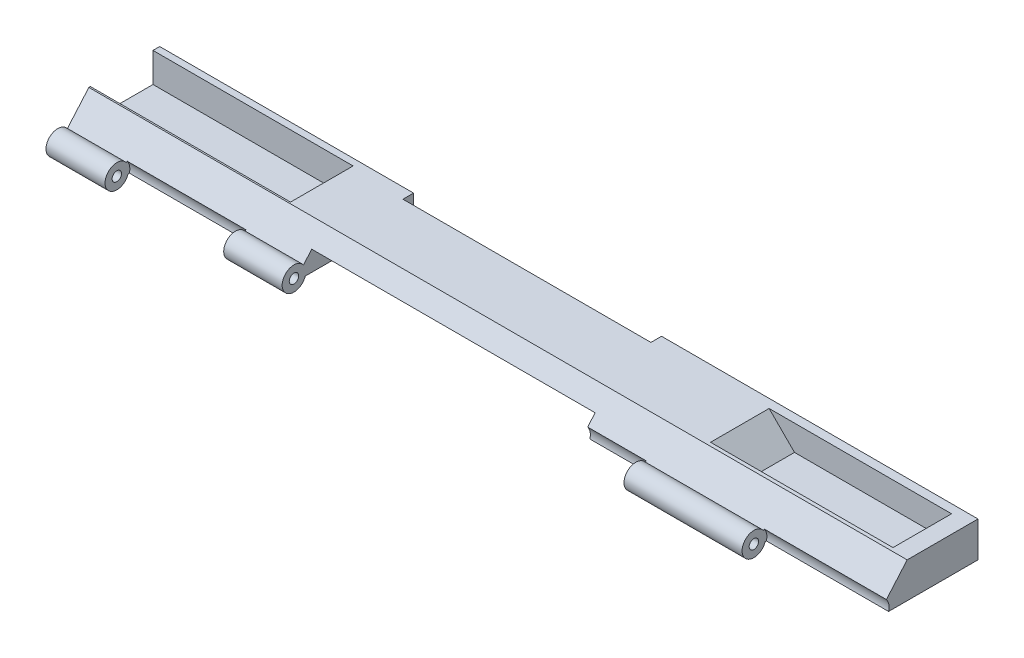
from build123d import *

# Parameters (mm, degrees)
SKETCH1_R                = 1.6002
SKETCH1_R_2              = 0.8128
BOSS_EXTRUDE5_DEPTH      = 162.56
CUT_EXTRUDE1_DEPTH       = 14.351
SKETCH3_W                = 0.889
SKETCH3_H                = 5.842
BOSS_EXTRUDE6_DEPTH      = 36.957
SKETCH16_W               = 13.462
SKETCH16_H               = 6.460130881
BOSS_EXTRUDE7_DEPTH      = 33.02
CUT_EXTRUDE4_DEPTH       = 15.24
SKETCH18_W               = 1.778
SKETCH18_H               = 5.842
BOSS_EXTRUDE8_DEPTH      = 38.1
CUT_EXTRUDE5_DEPTH       = 14.224
SKETCH20_W               = 2.1336
SKETCH20_H               = 5.461
BOSS_EXTRUDE9_DEPTH      = 36.322
SKETCH22_R               = 1.4224
CUT_EXTRUDE7_DEPTH       = 20.32
CUT_EXTRUDE7_DEPTH_BACK  = 24.13
SKETCH25_W               = 112.268
SKETCH25_H               = 3.007323321
CUT_EXTRUDE8_DEPTH       = 24.13
SKETCH27_R               = 1.778
CUT_EXTRUDE9_DEPTH       = 112.268
CUT_EXTRUDE12_DEPTH      = 14.224
SKETCH34_W               = 43.053
SKETCH34_H               = 2.1336
BOSS_EXTRUDE14_DEPTH     = 7.112
SKETCH35_R               = 1.4224
CUT_EXTRUDE13_DEPTH      = 7.112
SKETCH37_W               = 60.96
SKETCH37_H               = 15.24
CUT_EXTRUDE14_DEPTH      = 3.048
SKETCH38_R               = 0.8128
CUT_EXTRUDE15_DEPTH      = 5.08
SKETCH39_R               = 0.8128
CUT_EXTRUDE16_DEPTH      = 5.08
SKETCH40_W               = 60.96
SKETCH40_H               = 2.54
CUT_EXTRUDE17_DEPTH      = 3.048
SKETCH41_R               = 1.161307013
BOSS_EXTRUDE15_DEPTH     = 6.604
SKETCH42_R               = 1.020818471
BOSS_EXTRUDE16_DEPTH     = 5.588
SKETCH43_R               = 0.8128
CUT_EXTRUDE18_DEPTH      = 5.08
SKETCH44_R               = 0.8128
CUT_EXTRUDE19_DEPTH      = 5.08
SKETCH46_W               = 60.96
SKETCH46_H               = 9.087986699
CUT_EXTRUDE21_DEPTH      = 3.048
SKETCH47_W               = 53.34
SKETCH47_H               = 2.286
CUT_EXTRUDE22_DEPTH      = 15.24
SKETCH48_R               = 2.54
BOSS_EXTRUDE17_DEPTH     = 25.146
SKETCH49_R               = 2.54
BOSS_EXTRUDE18_DEPTH     = 25.146
SKETCH50_R               = 2.794
CUT_EXTRUDE23_DEPTH      = 112.268
SKETCH51_R               = 1.27
CUT_EXTRUDE24_DEPTH      = 174.498
CUT_EXTRUDE25_DEPTH      = 1.27
SKETCH55_W               = 46.703523857
SKETCH55_H               = 5.873481267
CUT_EXTRUDE26_DEPTH      = 9.144
CUT_EXTRUDE26_DEPTH_BACK = 8.636
SKETCH57_R               = 1.029255476
BOSS_EXTRUDE20_DEPTH     = 5.08
SKETCH58_R               = 1.09273592
BOSS_EXTRUDE21_DEPTH     = 7.112
SKETCH59_R               = 1.016
CUT_EXTRUDE27_DEPTH      = 66.04
CUT_EXTRUDE27_DEPTH_BACK = 5.08
SKETCH60_R               = 1.869467668
SKETCH60_R_2             = 1.016
BOSS_EXTRUDE22_DEPTH     = 162.56
SKETCH61_R               = 2.219373527
CUT_EXTRUDE28_DEPTH      = 112.268
SKETCH62_R               = 1.016
BOSS_EXTRUDE26_DEPTH     = 25.654
SKETCH65_R               = 1.016
BOSS_EXTRUDE27_DEPTH     = 25.654
SKETCH67_R               = 2.794
CUT_EXTRUDE32_DEPTH      = 12.827
SKETCH68_R               = 2.794
CUT_EXTRUDE33_DEPTH      = 12.827
SKETCH72_R               = 2.794
CUT_EXTRUDE34_DEPTH      = 25.654
BOSS_EXTRUDE28_DEPTH     = 0.127
SKETCH77_R               = 1.016
BOSS_EXTRUDE29_DEPTH     = 0.254
SKETCH79_R               = 1.016
CUT_EXTRUDE35_DEPTH      = 15.748
SKETCH87_W               = 23.622
SKETCH87_H               = 13.462
BOSS_EXTRUDE30_DEPTH     = 6.096
CUT_EXTRUDE36_DEPTH      = 14.9098
SKETCH89_W               = 1.4478
SKETCH89_H               = 6.35
BOSS_EXTRUDE31_DEPTH     = 30.6578
SKETCH92_W               = 12.0904
SKETCH92_H               = 7.62
BOSS_EXTRUDE33_DEPTH     = 43.18
BOSS_EXTRUDE34_DEPTH     = 13.462
SKETCH95_W               = 13.462
SKETCH95_H               = 6.35
CUT_EXTRUDE37_DEPTH      = 43.053
BOSS_EXTRUDE35_DEPTH     = 15.113
SKETCH97_W               = 12.5984
SKETCH97_H               = 5.461
CUT_EXTRUDE38_DEPTH      = 43.053
BOSS_EXTRUDE36_DEPTH     = 14.859
SKETCH99_W               = 12.5984
SKETCH99_H               = 5.461
BOSS_EXTRUDE37_DEPTH     = 3.81


with BuildPart() as part:
    # Sketch1 → Boss-Extrude5 (new body)
    with BuildSketch(Plane(origin=(0, 0, 0), x_dir=(0, 0, -1), z_dir=(1, 0, 0))):
        with BuildLine():
            ThreePointArc((11.4584801, -1.874600251), (11.409460099, -2.267640517), (11.265403421, -2.636600251))
            Line((11.265403421, -2.636600251), (11.4584801, -2.636600251))
            Line((11.4584801, -2.636600251), (31.7784801, -2.636600251))
            Line((31.7784801, -2.636600251), (31.7784801, 4.983399749))
            Line((31.7784801, 4.983399749), (16.5384801, 4.983399749))
            Line((16.5384801, 4.983399749), (11.265403421, -1.112600251))
            ThreePointArc((11.265403421, -1.112600251), (11.409460099, -1.481559985), (11.4584801, -1.874600251))
        make_face()
        with Locations((9.8582801, -1.874600251)):
            Circle(SKETCH1_R)
        with Locations((9.8582801, -1.874600251)):
            Circle(SKETCH1_R_2, mode=Mode.SUBTRACT)
    extrude(amount=BOSS_EXTRUDE5_DEPTH)

    # Sketch2 → Cut-Extrude1 (cut)
    with BuildSketch(Plane(origin=(0, 0, -31.7784801), x_dir=(-1, 0, 0), z_dir=(0, 0, -1))):
        Polygon((0, 4.983399749), (0, -0.858600251), (-17.78, -0.858600251), (-23.622, 4.983399749), align=None)
    extrude(amount=-CUT_EXTRUDE1_DEPTH, mode=Mode.SUBTRACT)

    # Sketch3 → Boss-Extrude6 (add)
    with BuildSketch(Plane.ZY):
        with Locations((-31.3339801, 2.062399749)):
            Rectangle(SKETCH3_W, SKETCH3_H)
    extrude(amount=-BOSS_EXTRUDE6_DEPTH)

    # Sketch16 → Boss-Extrude7 (add)
    with BuildSketch(Plane.ZY):
        with Locations((-24.1584801, 1.753334308)):
            Rectangle(SKETCH16_W, SKETCH16_H)
    extrude(amount=-BOSS_EXTRUDE7_DEPTH)

    # Sketch17 → Cut-Extrude4 (cut)
    with BuildSketch(Plane(origin=(0, 0, -31.7784801), x_dir=(-1, 0, 0), z_dir=(0, 0, -1))):
        Polygon((0, 4.983399749), (0, -0.858600251), (-17.78, -0.858600251), (-23.622, 4.983399749), align=None)
    extrude(amount=-CUT_EXTRUDE4_DEPTH, mode=Mode.SUBTRACT)

    # Sketch18 → Boss-Extrude8 (add)
    with BuildSketch(Plane.ZY):
        with Locations((-30.8894801, 2.062399749)):
            Rectangle(SKETCH18_W, SKETCH18_H)
    extrude(amount=-BOSS_EXTRUDE8_DEPTH)

    # Sketch19 → Cut-Extrude5 (cut)
    with BuildSketch(Plane(origin=(0, 0, -31.7784801), x_dir=(-1, 0, 0), z_dir=(0, 0, -1))):
        Polygon((-162.56, 4.983399749), (-162.56, -0.477600251), (-142.24, -0.477600251), (-136.779, 4.983399749), align=None)
    extrude(amount=-CUT_EXTRUDE5_DEPTH, mode=Mode.SUBTRACT)

    # Sketch20 → Boss-Extrude9 (add)
    with BuildSketch(Plane(origin=(162.56, 0, 0), x_dir=(0, 0, -1), z_dir=(1, 0, 0))):
        with Locations((30.7116801, 2.252899749)):
            Rectangle(SKETCH20_W, SKETCH20_H)
    extrude(amount=-BOSS_EXTRUDE9_DEPTH)

    # Sketch22 → Cut-Extrude7 (cut, two sides)
    with BuildSketch(Plane(origin=(0, -0.477600251, 0), x_dir=(1, 0, 0), z_dir=(0, 1, 0))) as cut_extrude7_sk:
        with Locations((145.9484, 26.5714801)):
            Circle(SKETCH22_R)
        with BuildLine():
            ThreePointArc((147.3708, 26.5714801), (146.954188686, 25.565691415), (145.9484, 25.1490801))
            Line((145.9484, 25.1490801), (157.217057139, 25.1490801))
            ThreePointArc((157.217057139, 25.1490801), (155.794657139, 26.5714801), (157.217057139, 27.9938801))
            Line((157.217057139, 27.9938801), (145.9484, 27.9938801))
            ThreePointArc((145.9484, 27.9938801), (146.954188686, 27.577268786), (147.3708, 26.5714801))
        make_face()
        with Locations((157.217057139, 26.5714801)):
            Circle(SKETCH22_R)
        with BuildLine():
            ThreePointArc((157.217057139, 19.1292801), (155.794657139, 20.5516801), (157.217057139, 21.9740801))
            Line((157.217057139, 21.9740801), (145.9484, 21.9740801))
            ThreePointArc((145.9484, 21.9740801), (146.954188686, 21.557468786), (147.3708, 20.5516801))
            ThreePointArc((147.3708, 20.5516801), (146.954188686, 19.545891415), (145.9484, 19.1292801))
            Line((145.9484, 19.1292801), (157.217057139, 19.1292801))
        make_face()
        with Locations((157.217057139, 20.5516801)):
            Circle(SKETCH22_R)
        with Locations((145.9484, 20.5516801)):
            Circle(SKETCH22_R)
    extrude(amount=CUT_EXTRUDE7_DEPTH, mode=Mode.SUBTRACT)
    extrude(cut_extrude7_sk.sketch, amount=-CUT_EXTRUDE7_DEPTH_BACK, mode=Mode.SUBTRACT)

    # Sketch25 → Cut-Extrude8 (cut)
    with BuildSketch(Plane(origin=(0, 4.983399749, 0), x_dir=(1, 0, 0), z_dir=(0, 1, 0))):
        with Locations((81.28, 9.761741761)):
            Rectangle(SKETCH25_W, SKETCH25_H)
    extrude(amount=-CUT_EXTRUDE8_DEPTH, mode=Mode.SUBTRACT)

    # Sketch27 → Cut-Extrude9 (cut)
    with BuildSketch(Plane.ZY.offset(-137.414)):
        with Locations((-9.8582801, -1.874600251)):
            Circle(SKETCH27_R)
    extrude(amount=CUT_EXTRUDE9_DEPTH, mode=Mode.SUBTRACT)

    # Sketch31 → Cut-Extrude12 (cut)
    with BuildSketch(Plane(origin=(0, 0, -31.7784801), x_dir=(-1, 0, 0), z_dir=(0, 0, -1))):
        Polygon((-162.56, 4.983399749), (-162.56, -0.477600251), (-124.968, -0.477600251), (-119.507, 4.983399749), (-124.079, 4.983399749), align=None)
    extrude(amount=-CUT_EXTRUDE12_DEPTH, mode=Mode.SUBTRACT)

    # Sketch34 → Boss-Extrude14 (add)
    with BuildSketch(Plane(origin=(0, 4.983399749, 0), x_dir=(1, 0, 0), z_dir=(0, 1, 0))):
        with Locations((141.0335, 30.7116801)):
            Rectangle(SKETCH34_W, SKETCH34_H)
    extrude(amount=-BOSS_EXTRUDE14_DEPTH)

    # Sketch35 → Cut-Extrude13 (cut)
    with BuildSketch(Plane(origin=(0, -0.477600251, 0), x_dir=(1, 0, 0), z_dir=(0, 1, 0))):
        with BuildLine():
            Line((130.048, 25.1490801), (145.9484, 25.1490801))
            ThreePointArc((145.9484, 25.1490801), (144.526, 26.5714801), (145.9484, 27.9938801))
            Line((145.9484, 27.9938801), (130.048, 27.9938801))
            ThreePointArc((130.048, 27.9938801), (131.053788686, 27.577268786), (131.4704, 26.5714801))
            ThreePointArc((131.4704, 26.5714801), (131.053788686, 25.565691415), (130.048, 25.1490801))
        make_face()
        with BuildLine():
            ThreePointArc((145.9484, 19.1292801), (144.526, 20.5516801), (145.9484, 21.9740801))
            Line((145.9484, 21.9740801), (130.048, 21.9740801))
            ThreePointArc((130.048, 21.9740801), (131.053788686, 21.557468786), (131.4704, 20.5516801))
            ThreePointArc((131.4704, 20.5516801), (131.053788686, 19.545891415), (130.048, 19.1292801))
            Line((130.048, 19.1292801), (145.9484, 19.1292801))
        make_face()
        with Locations((130.048, 20.5516801)):
            Circle(SKETCH35_R)
        with Locations((130.048, 26.5714801)):
            Circle(SKETCH35_R)
    extrude(amount=-CUT_EXTRUDE13_DEPTH, mode=Mode.SUBTRACT)

    # Sketch37 → Cut-Extrude14 (cut)
    with BuildSketch(Plane(origin=(0, -2.636600251, 0), x_dir=(-1, 0, 0), z_dir=(0, -1, 0))):
        with Locations((-81.28, 21.6184801)):
            Rectangle(SKETCH37_W, SKETCH37_H)
    extrude(amount=-CUT_EXTRUDE14_DEPTH, mode=Mode.SUBTRACT)

    # Sketch38 → Cut-Extrude15 (cut)
    with BuildSketch(Plane.ZY.offset(-111.76)):
        with Locations((-27.9684801, -1.112600251)):
            Circle(SKETCH38_R)
    extrude(amount=-CUT_EXTRUDE15_DEPTH, mode=Mode.SUBTRACT)

    # Sketch39 → Cut-Extrude16 (cut)
    with BuildSketch(Plane(origin=(50.8, 0, 0), x_dir=(0, 0, -1), z_dir=(1, 0, 0))):
        with Locations(Location((27.9684801, -1.112600251, 0), (0, 0, 180))):
            Circle(SKETCH39_R)
    extrude(amount=-CUT_EXTRUDE16_DEPTH, mode=Mode.SUBTRACT)

    # Sketch40 → Cut-Extrude17 (cut)
    with BuildSketch(Plane(origin=(0, -2.636600251, 0), x_dir=(-1, 0, 0), z_dir=(0, -1, 0))):
        with Locations((-81.28, 30.5084801)):
            Rectangle(SKETCH40_W, SKETCH40_H)
    extrude(amount=-CUT_EXTRUDE17_DEPTH, mode=Mode.SUBTRACT)

    # Sketch41 → Boss-Extrude15 (add)
    with BuildSketch(Plane(origin=(50.8, 0, 0), x_dir=(0, 0, -1), z_dir=(1, 0, 0))):
        with Locations((27.9684801, -1.112600251)):
            Circle(SKETCH41_R)
    extrude(amount=-BOSS_EXTRUDE15_DEPTH)

    # Sketch42 → Boss-Extrude16 (add)
    with BuildSketch(Plane.ZY.offset(-111.76)):
        with Locations((-27.9684801, -1.112600251)):
            Circle(SKETCH42_R)
    extrude(amount=-BOSS_EXTRUDE16_DEPTH)

    # Sketch43 → Cut-Extrude18 (cut)
    with BuildSketch(Plane(origin=(50.8, 0, 0), x_dir=(0, 0, -1), z_dir=(1, 0, 0))):
        with Locations((30.5084801, -1.112600251)):
            Circle(SKETCH43_R)
    extrude(amount=-CUT_EXTRUDE18_DEPTH, mode=Mode.SUBTRACT)

    # Sketch44 → Cut-Extrude19 (cut)
    with BuildSketch(Plane.ZY.offset(-111.76)):
        with Locations(Location((-30.5084801, -1.112600251, 0), (0, 0, 180))):
            Circle(SKETCH44_R)
    extrude(amount=-CUT_EXTRUDE19_DEPTH, mode=Mode.SUBTRACT)

    # Sketch46 → Cut-Extrude21 (cut)
    with BuildSketch(Plane(origin=(0, -2.636600251, 0), x_dir=(-1, 0, 0), z_dir=(0, -1, 0))):
        with Locations((-81.28, 9.45448675)):
            Rectangle(SKETCH46_W, SKETCH46_H)
    extrude(amount=-CUT_EXTRUDE21_DEPTH, mode=Mode.SUBTRACT)

    # Sketch47 → Cut-Extrude22 (cut)
    with BuildSketch(Plane(origin=(0, 0.411399749, 0), x_dir=(-1, 0, 0), z_dir=(0, -1, 0))):
        with Locations((-81.28, 30.6354801)):
            Rectangle(SKETCH47_W, SKETCH47_H)
    extrude(amount=-CUT_EXTRUDE22_DEPTH, mode=Mode.SUBTRACT)

    # Sketch48 → Boss-Extrude17 (add)
    with BuildSketch(Plane.ZY):
        with Locations((-9.8582801, -1.874600251)):
            Circle(SKETCH48_R)
    extrude(amount=-BOSS_EXTRUDE17_DEPTH)

    # Sketch49 → Boss-Extrude18 (add)
    with BuildSketch(Plane(origin=(162.56, 0, 0), x_dir=(0, 0, -1), z_dir=(1, 0, 0))):
        with Locations((9.8582801, -1.874600251)):
            Circle(SKETCH49_R)
    extrude(amount=-BOSS_EXTRUDE18_DEPTH)

    # Sketch50 → Cut-Extrude23 (cut)
    with BuildSketch(Plane.ZY.offset(-137.414)):
        with Locations((-9.8582801, -1.874600251)):
            Circle(SKETCH50_R)
    extrude(amount=CUT_EXTRUDE23_DEPTH, mode=Mode.SUBTRACT)

    # Sketch51 → Cut-Extrude24 (cut)
    with BuildSketch(Plane(origin=(162.56, 0, 0), x_dir=(0, 0, -1), z_dir=(1, 0, 0))):
        with Locations((9.8582801, -1.874600251)):
            Circle(SKETCH51_R)
    extrude(amount=-CUT_EXTRUDE24_DEPTH, mode=Mode.SUBTRACT)

    # Sketch52 → Cut-Extrude25 (cut)
    with BuildSketch(Plane(origin=(0, 0.411399749, 0), x_dir=(-1, 0, 0), z_dir=(0, -1, 0))):
        Polygon((-50.8, 31.7784801), (-50.8, 12.546363432), (-111.76, 12.6522801), (-111.76, 31.7784801), align=None)
    extrude(amount=-CUT_EXTRUDE25_DEPTH, mode=Mode.SUBTRACT)

    # Sketch55 → Cut-Extrude26 (cut, two sides)
    with BuildSketch(Plane.XZ.offset(2.636600251)) as cut_extrude26_sk:
        with Locations((88.408238071, -10.745489599)):
            Rectangle(SKETCH55_W, SKETCH55_H)
    extrude(amount=CUT_EXTRUDE26_DEPTH, mode=Mode.SUBTRACT)
    extrude(cut_extrude26_sk.sketch, amount=-CUT_EXTRUDE26_DEPTH_BACK, mode=Mode.SUBTRACT)

    # Sketch57 → Boss-Extrude20 (add)
    with BuildSketch(Plane(origin=(45.72, 0, 0), x_dir=(0, 0, -1), z_dir=(1, 0, 0))):
        with Locations((30.5084801, -1.112600251)):
            Circle(SKETCH57_R)
    extrude(amount=BOSS_EXTRUDE20_DEPTH)

    # Sketch58 → Boss-Extrude21 (add)
    with BuildSketch(Plane.ZY.offset(-111.76)):
        with Locations((-30.5084801, -1.112600251)):
            Circle(SKETCH58_R)
    extrude(amount=-BOSS_EXTRUDE21_DEPTH)

    # Sketch59 → Cut-Extrude27 (cut, two sides)
    with BuildSketch(Plane(origin=(50.8, 0, 0), x_dir=(0, 0, -1), z_dir=(1, 0, 0))) as cut_extrude27_sk:
        with Locations((29.2384801, -0.477600251)):
            Circle(SKETCH59_R)
    extrude(amount=CUT_EXTRUDE27_DEPTH, mode=Mode.SUBTRACT)
    extrude(cut_extrude27_sk.sketch, amount=-CUT_EXTRUDE27_DEPTH_BACK, mode=Mode.SUBTRACT)

    # Sketch60 → Boss-Extrude22 (add)
    with BuildSketch(Plane.ZY):
        with Locations((-9.8582801, -1.874600251)):
            Circle(SKETCH60_R)
        with Locations((-9.8582801, -1.874600251)):
            Circle(SKETCH60_R_2, mode=Mode.SUBTRACT)
    extrude(amount=-BOSS_EXTRUDE22_DEPTH)

    # Sketch61 → Cut-Extrude28 (cut)
    with BuildSketch(Plane.ZY.offset(-137.414)):
        with Locations((-9.8582801, -1.874600251)):
            Circle(SKETCH61_R)
    extrude(amount=CUT_EXTRUDE28_DEPTH, mode=Mode.SUBTRACT)

    # Sketch62 → Boss-Extrude26 (add)
    with BuildSketch(Plane(origin=(25.146, 0, 0), x_dir=(0, 0, -1), z_dir=(1, 0, 0))):
        with BuildLine():
            Line((12.07614536, -0.175332853), (11.906096413, -0.371919863))
            ThreePointArc((11.906096413, -0.371919863), (12.272100043, -1.083984489), (12.3982801, -1.874600251))
            ThreePointArc((12.3982801, -1.874600251), (12.368861124, -2.260064807), (12.281285672, -2.636600251))
            Line((12.281285672, -2.636600251), (12.546363432, -2.636600251))
            ThreePointArc((12.546363432, -2.636600251), (12.602645637, -1.350297092), (12.07614536, -0.175332853))
        make_face()
        with BuildLine():
            ThreePointArc((12.3982801, -1.874600251), (12.272100043, -1.083984489), (11.906096413, -0.371919863))
            ThreePointArc((11.906096413, -0.371919863), (7.352435653, -2.289743123), (12.281285672, -2.636600251))
            ThreePointArc((12.281285672, -2.636600251), (12.368861124, -2.260064807), (12.3982801, -1.874600251))
        make_face()
        with Locations(Location((9.8582801, -1.874600251, 0), (0, 0, 180))):
            Circle(SKETCH62_R, mode=Mode.SUBTRACT)
    extrude(amount=BOSS_EXTRUDE26_DEPTH)

    # Sketch65 → Boss-Extrude27 (add)
    with BuildSketch(Plane.ZY.offset(-137.414)):
        with BuildLine():
            ThreePointArc((-12.281285672, -2.636600251), (-12.364124548, -1.459457379), (-11.906096413, -0.371919863))
            Line((-11.906096413, -0.371919863), (-12.07614536, -0.175332853))
            ThreePointArc((-12.07614536, -0.175332853), (-12.602645637, -1.350297092), (-12.546363432, -2.636600251))
            Line((-12.546363432, -2.636600251), (-12.281285672, -2.636600251))
        make_face()
        with BuildLine():
            ThreePointArc((-7.3182801, -1.874600251), (-9.067664339, 0.539219692), (-11.906096413, -0.371919863))
            ThreePointArc((-11.906096413, -0.371919863), (-12.364124548, -1.459457379), (-12.281285672, -2.636600251))
            ThreePointArc((-12.281285672, -2.636600251), (-9.472815544, -4.385181275), (-7.3182801, -1.874600251))
        make_face()
        with Locations((-9.8582801, -1.874600251)):
            Circle(SKETCH65_R, mode=Mode.SUBTRACT)
    extrude(amount=BOSS_EXTRUDE27_DEPTH)

    # Sketch67 → Cut-Extrude32 (cut)
    with BuildSketch(Plane(origin=(162.56, 0, 0), x_dir=(0, 0, -1), z_dir=(1, 0, 0))):
        with Locations((9.8582801, -1.874600251)):
            Circle(SKETCH67_R)
    extrude(amount=-CUT_EXTRUDE32_DEPTH, mode=Mode.SUBTRACT)

    # Sketch68 → Cut-Extrude33 (cut)
    with BuildSketch(Plane.ZY.offset(-111.76)):
        with Locations((-9.8582801, -1.874600251)):
            Circle(SKETCH68_R)
    extrude(amount=-CUT_EXTRUDE33_DEPTH, mode=Mode.SUBTRACT)

    # Sketch72 → Cut-Extrude34 (cut)
    with BuildSketch(Plane.ZY.offset(-12.573)):
        with Locations((-9.8582801, -1.874600251)):
            Circle(SKETCH72_R)
    extrude(amount=-CUT_EXTRUDE34_DEPTH, mode=Mode.SUBTRACT)

    # Sketch74 → Boss-Extrude28 (add)
    with BuildSketch(Plane.ZY.offset(-12.573)):
        with BuildLine():
            Line((-12.546363432, -2.636600251), (-12.281285672, -2.636600251))
            ThreePointArc((-12.281285672, -2.636600251), (-7.352435653, -2.289743123), (-11.906096413, -0.371919863))
            Line((-11.906096413, -0.371919863), (-12.07614536, -0.175332853))
            ThreePointArc((-12.07614536, -0.175332853), (-12.602645637, -1.350297092), (-12.546363432, -2.636600251))
        make_face()
    extrude(amount=-BOSS_EXTRUDE28_DEPTH)

    # Sketch77 → Boss-Extrude29 (add)
    with BuildSketch(Plane.ZY.offset(-124.587)):
        with BuildLine():
            ThreePointArc((-11.906096413, -0.371919863), (-12.364124548, -1.459457379), (-12.281285672, -2.636600251))
            ThreePointArc((-12.281285672, -2.636600251), (-9.472815544, -4.385181275), (-7.3182801, -1.874600251))
            ThreePointArc((-7.3182801, -1.874600251), (-9.067664339, 0.539219692), (-11.906096413, -0.371919863))
        make_face()
        with Locations((-9.8582801, -1.874600251)):
            Circle(SKETCH77_R, mode=Mode.SUBTRACT)
        with BuildLine():
            Line((-12.546363432, -2.636600251), (-12.281285672, -2.636600251))
            ThreePointArc((-12.281285672, -2.636600251), (-12.364124548, -1.459457379), (-11.906096413, -0.371919863))
            Line((-11.906096413, -0.371919863), (-12.07614536, -0.175332853))
            ThreePointArc((-12.07614536, -0.175332853), (-12.602645637, -1.350297092), (-12.546363432, -2.636600251))
        make_face()
    extrude(amount=BOSS_EXTRUDE29_DEPTH)

    # Sketch79 → Cut-Extrude35 (cut)
    with BuildSketch(Plane.ZY):
        with Locations((-9.8582801, -1.874600251)):
            Circle(SKETCH79_R)
    extrude(amount=-CUT_EXTRUDE35_DEPTH, mode=Mode.SUBTRACT)

    # Sketch87 → Boss-Extrude30 (add)
    with BuildSketch(Plane(origin=(0, 4.983399749, 0), x_dir=(1, 0, 0), z_dir=(0, 1, 0))):
        with Locations((11.811, 23.2694801)):
            Rectangle(SKETCH87_W, SKETCH87_H)
    extrude(amount=-BOSS_EXTRUDE30_DEPTH)

    # Sketch88 → Cut-Extrude36 (cut)
    with BuildSketch(Plane(origin=(0, 0, -31.7784801), x_dir=(-1, 0, 0), z_dir=(0, 0, -1))):
        Polygon((0, 4.983399749), (0, -1.366600251), (-17.78, -1.366600251), (-23.622, 4.983399749), align=None)
    extrude(amount=-CUT_EXTRUDE36_DEPTH, mode=Mode.SUBTRACT)

    # Sketch89 → Boss-Extrude31 (add)
    with BuildSketch(Plane.ZY):
        with Locations((-31.0545801, 1.808399749)):
            Rectangle(SKETCH89_W, SKETCH89_H)
    extrude(amount=-BOSS_EXTRUDE31_DEPTH)

    # Sketch92 → Boss-Extrude33 (add)
    with BuildSketch(Plane(origin=(162.56, 0, 0), x_dir=(0, 0, -1), z_dir=(1, 0, 0))):
        with Locations((23.5996801, 1.173399749)):
            Rectangle(SKETCH92_W, SKETCH92_H)
    extrude(amount=-BOSS_EXTRUDE33_DEPTH)

    # Sketch94 → Boss-Extrude34 (add)
    with BuildSketch(Plane(origin=(162.56, 0, 0), x_dir=(0, 0, -1), z_dir=(1, 0, 0))):
        with BuildLine():
            ThreePointArc((12.07614536, -0.175332853), (12.602645637, -1.350297092), (12.546363432, -2.636600251))
            Line((12.546363432, -2.636600251), (31.7784801, -2.636600251))
            Line((31.7784801, -2.636600251), (31.7784801, 4.983399749))
            Line((31.7784801, 4.983399749), (16.5384801, 4.983399749))
            Line((16.5384801, 4.983399749), (12.07614536, -0.175332853))
        make_face()
    extrude(amount=BOSS_EXTRUDE34_DEPTH)

    # Sketch95 → Cut-Extrude37 (cut)
    with BuildSketch(Plane.ZY):
        with Locations((-23.5996801, 1.808399749)):
            Rectangle(SKETCH95_W, SKETCH95_H)
    extrude(amount=-CUT_EXTRUDE37_DEPTH, mode=Mode.SUBTRACT)

    # Sketch96 → Boss-Extrude35 (add)
    with BuildSketch(Plane(origin=(0, 0, -31.7784801), x_dir=(-1, 0, 0), z_dir=(0, 0, -1))):
        Polygon((-35.840922937, -2.228677314), (-43.053, -2.228677314), (-43.053, 4.983399749), align=None)
    extrude(amount=-BOSS_EXTRUDE35_DEPTH)

    # Sketch97 → Cut-Extrude38 (cut)
    with BuildSketch(Plane(origin=(176.022, 0, 0), x_dir=(0, 0, -1), z_dir=(1, 0, 0))):
        with Locations((23.5996801, 2.252899749)):
            Rectangle(SKETCH97_W, SKETCH97_H)
    extrude(amount=-CUT_EXTRUDE38_DEPTH, mode=Mode.SUBTRACT)

    # Sketch98 → Boss-Extrude36 (add)
    with BuildSketch(Plane(origin=(0, 0, -31.7784801), x_dir=(-1, 0, 0), z_dir=(0, 0, -1))):
        Polygon((-132.969, 4.983399749), (-139.89015762, -1.937757871), (-132.969, -1.937757871), align=None)
    extrude(amount=-BOSS_EXTRUDE36_DEPTH)

    # Sketch99 → Boss-Extrude37 (add)
    with BuildSketch(Plane(origin=(176.022, 0, 0), x_dir=(0, 0, -1), z_dir=(1, 0, 0))):
        with Locations((23.5996801, 2.252899749)):
            Rectangle(SKETCH99_W, SKETCH99_H)
    extrude(amount=-BOSS_EXTRUDE37_DEPTH)


solid = part.part
